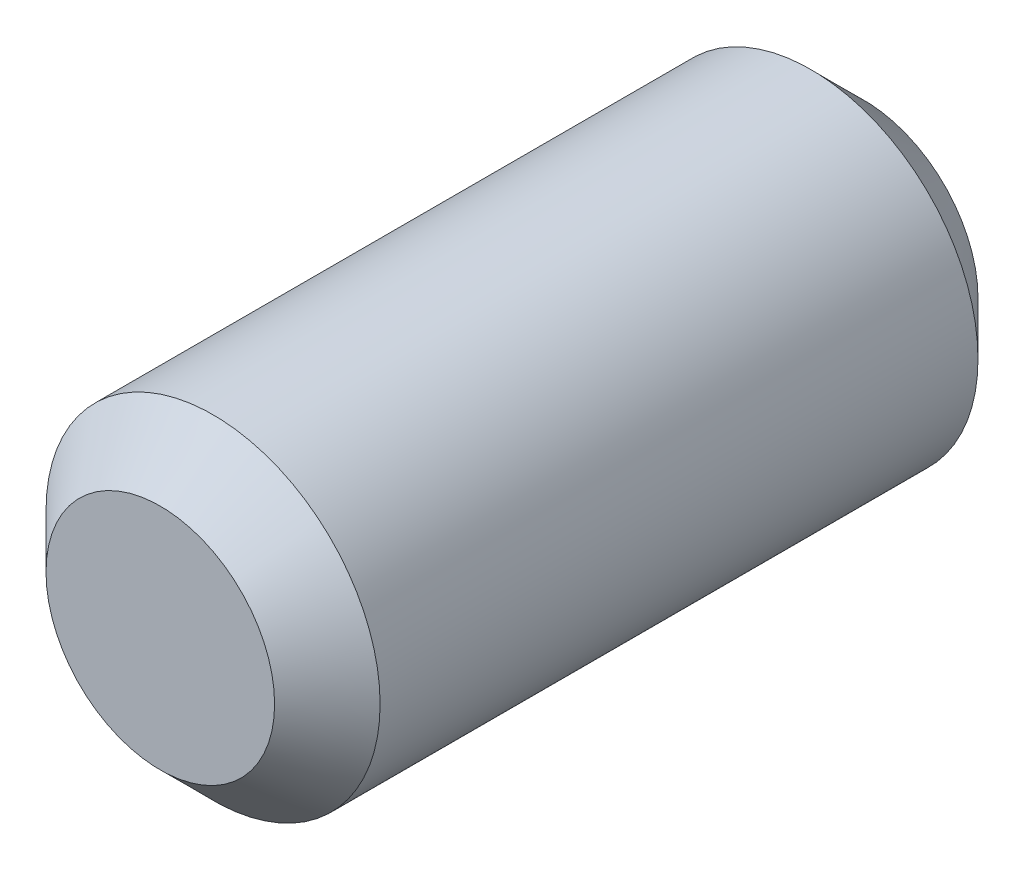
from build123d import *

# Parameters (mm, degrees)
SKETCH1_R           = 4.75
BOSS_EXTRUDE1_DEPTH = 20
CHAMFER1_SIZE       = 1.5
CHAMFER2_SIZE       = 1.5
SCALE1_SCALE        = 0.75
SCALE2_SCALE        = 0.85


with BuildPart() as part:
    # Sketch1 → Boss-Extrude1 (new body)
    with BuildSketch(Plane(origin=(0, 0, 0), x_dir=(0, 1, 0), z_dir=(0, 0, 1))):
        Circle(SKETCH1_R)
    extrude(amount=BOSS_EXTRUDE1_DEPTH)

    # Chamfer1
    chamfer1_edges = [part.edges().sort_by_distance(p)[0] for p in [
        (0, -4.75, 0),
    ]]
    chamfer(chamfer1_edges, length=CHAMFER1_SIZE)

    # Chamfer2
    chamfer2_edges = [part.edges().sort_by_distance(p)[0] for p in [
        (0, -4.75, 20),
    ]]
    chamfer(chamfer2_edges, length=CHAMFER2_SIZE)


with BuildPart() as part_1:
    # Scale1: scaled about (0, 0, 10)
    add(part.part.scale(SCALE1_SCALE).moved(Location((0, 0, 2.5))))


with BuildPart() as part_2:
    # Scale2: scaled about (0, 0, 10)
    add(part_1.part.scale(SCALE2_SCALE).moved(Location((0, 0, 1.5))))


solid = part_2.part
